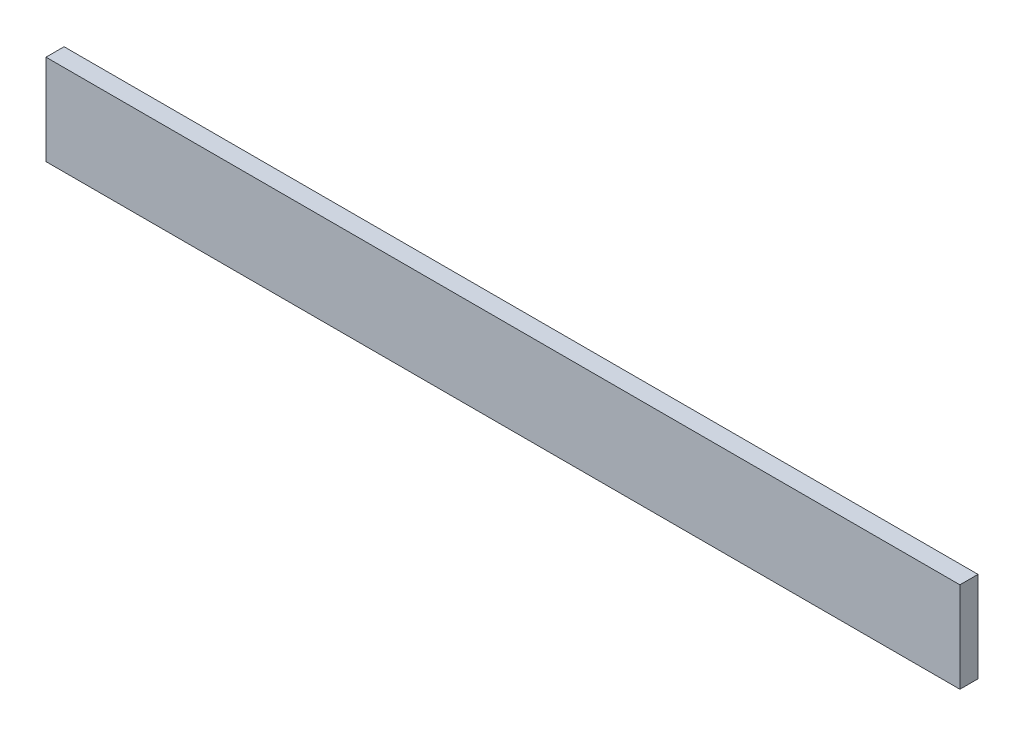
from build123d import *

# Parameters (mm, degrees)
SKETCH_1_W      = 505
SKETCH_1_H      = 50
EXTRUDE_1_DEPTH = 10


with BuildPart() as part:
    # Эскиз1 → Бобышка-Вытянуть1 (new body)
    with BuildSketch(Plane.XY):
        with Locations((252.5, 25)):
            Rectangle(SKETCH_1_W, SKETCH_1_H)
    extrude(amount=EXTRUDE_1_DEPTH)


solid = part.part
